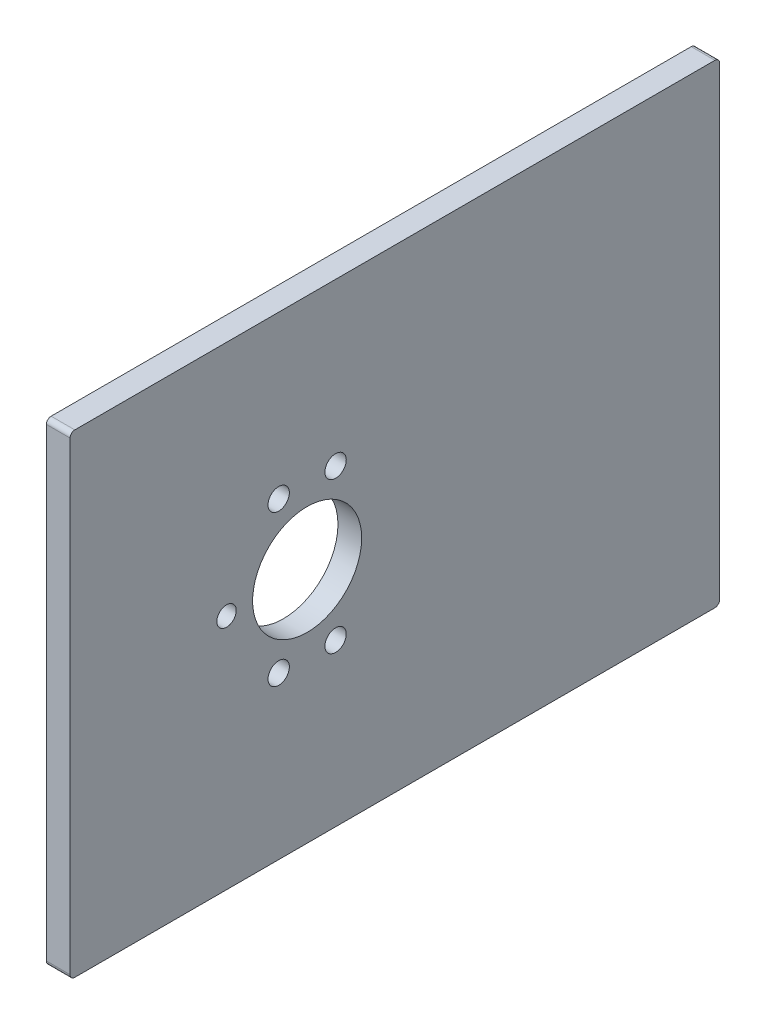
from build123d import *

# Parameters (mm, degrees)
SKIZZE1_R                       = 11.5
SKIZZE1_R_2                     = 2.25
SKIZZE1_R_3                     = 2.05
AUFSATZ_LINEAR_AUSTRAGEN1_DEPTH = 5
VERRUNDUNG1_R                   = 1


with BuildPart() as part:
    # Skizze1 → Aufsatz-Linear austragen1 (new body)
    with BuildSketch(Plane(origin=(0, 0, 0), x_dir=(0, 0, -1), z_dir=(1, 0, 0))):
        Polygon((-92, 59.908196572), (-192, 59.908196572), (-192, -40.091803428), (-92, -40.091803428), (-55, -40.091803428), (-55, 59.908196572), align=None)
        with Locations((-142, 9.908196572)):
            Circle(SKIZZE1_R, mode=Mode.SUBTRACT)
        with Locations((-148, 25.814170293)):
            Circle(SKIZZE1_R_2, mode=Mode.SUBTRACT)
        with Locations((-136, 25.814170293)):
            Circle(SKIZZE1_R_2, mode=Mode.SUBTRACT)
        with Locations((-159, 9.908196572)):
            Circle(SKIZZE1_R_3, mode=Mode.SUBTRACT)
        with Locations((-148, -5.997777148)):
            Circle(SKIZZE1_R_2, mode=Mode.SUBTRACT)
        with Locations((-136, -5.997777148)):
            Circle(SKIZZE1_R_2, mode=Mode.SUBTRACT)
    extrude(amount=AUFSATZ_LINEAR_AUSTRAGEN1_DEPTH)

    # Verrundung1
    verrundung1_edges = [part.edges().sort_by_distance(p)[0] for p in [
        (2.5, 59.908196572, 192),
        (2.5, 59.908196572, 55),
        (2.5, -40.091803428, 55),
        (2.5, -40.091803428, 192),
    ]]
    fillet(verrundung1_edges, radius=VERRUNDUNG1_R)


solid = part.part
